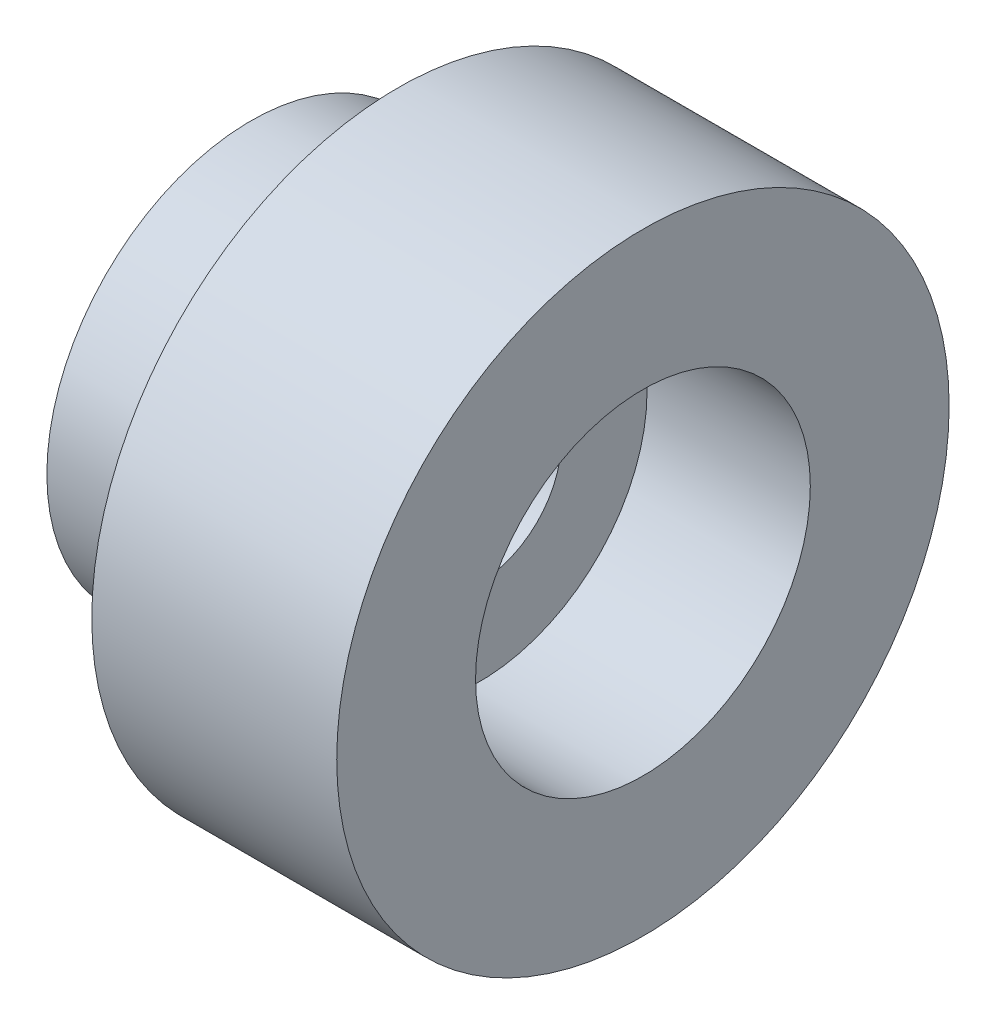
from build123d import *


with BuildPart() as part:
    # Sketch1 → Revolve1 (revolve)
    with BuildSketch(Plane.XY):
        Polygon((0, 1), (2.8, 1), (2.8, 2.05), (4.8, 2.05), (4.8, 3.75), (1.8, 3.75), (1.8, 2.5), (0, 2.5), align=None)
    revolve(axis=Axis((0, 0, 0), (1, 0, 0)))


solid = part.part
